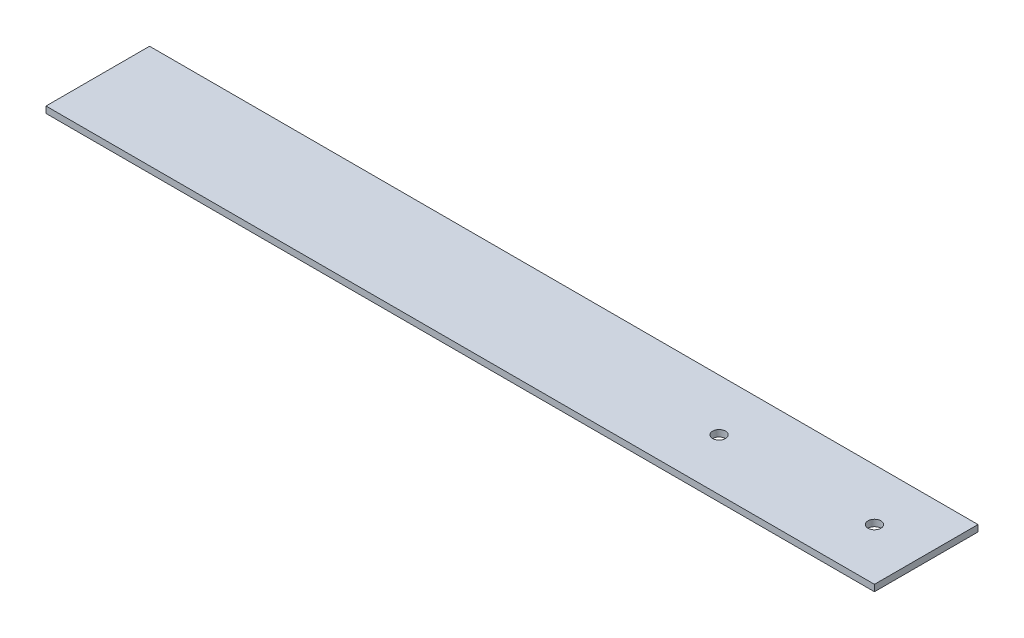
from build123d import *

# Parameters (mm, degrees)
SKETCH1_W           = 406.4
SKETCH1_H           = 50.8
BOSS_EXTRUDE1_DEPTH = 3.175
SKETCH2_R           = 3.175
CUT_EXTRUDE1_DEPTH  = 4.175


with BuildPart() as part:
    # Sketch1 → Boss-Extrude1 (new body)
    with BuildSketch(Plane(origin=(0, 0, 0), x_dir=(1, 0, 0), z_dir=(0, 1, 0))):
        with Locations((203.2, 25.4)):
            Rectangle(SKETCH1_W, SKETCH1_H)
    extrude(amount=BOSS_EXTRUDE1_DEPTH)

    # Sketch2 → Cut-Extrude1 (cut, through all)
    with BuildSketch(Plane(origin=(0, 3.175, 0), x_dir=(1, 0, 0), z_dir=(0, 1, 0))):
        with Locations((381, 25.4)):
            Circle(SKETCH2_R)
        with Locations((304.8, 25.4)):
            Circle(SKETCH2_R)
    extrude(amount=-CUT_EXTRUDE1_DEPTH, mode=Mode.SUBTRACT)


solid = part.part
